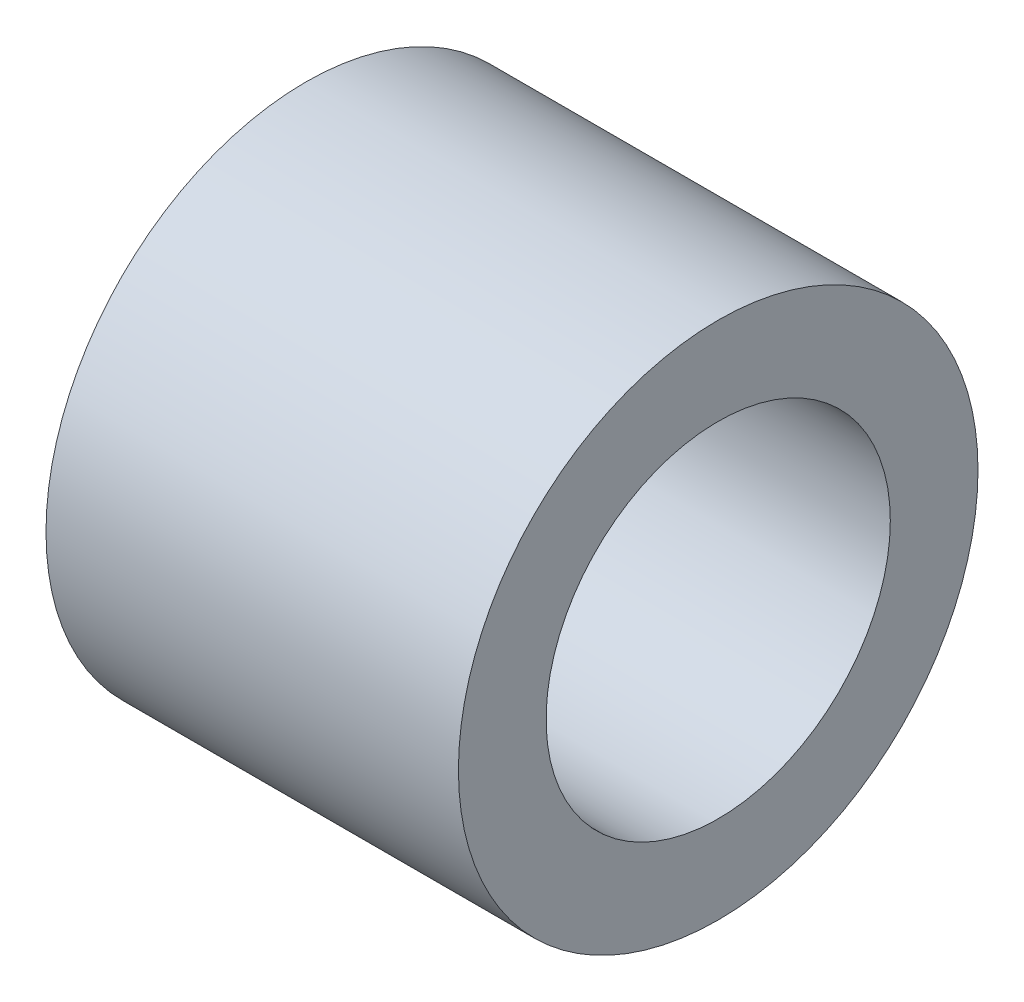
from build123d import *

# Parameters (mm, degrees)
SKETCH1_R           = 4
SKETCH1_R_2         = 2.65
BOSS_EXTRUDE1_DEPTH = 6.35


with BuildPart() as part:
    # Sketch1 → Boss-Extrude1 (new body)
    with BuildSketch(Plane(origin=(0, 0, 0), x_dir=(0, 0, -1), z_dir=(1, 0, 0))):
        Circle(SKETCH1_R)
        Circle(SKETCH1_R_2, mode=Mode.SUBTRACT)
    extrude(amount=BOSS_EXTRUDE1_DEPTH)


solid = part.part
